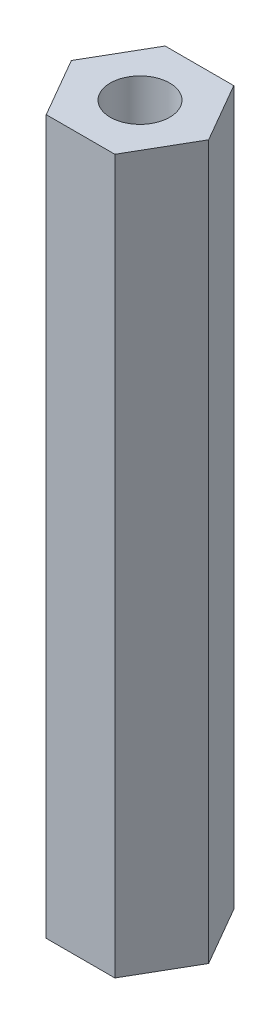
from build123d import *

# Parameters (mm, degrees)
SKETCH1_R           = 3.175
BOSS_EXTRUDE1_DEPTH = 38.1


with BuildPart() as part:
    # Sketch1 → Boss-Extrude1 (new body, symmetric)
    with BuildSketch(Plane(origin=(0, 0, 0), x_dir=(1, 0, 0), z_dir=(0, 1, 0))):
        Polygon((3.666174209, -6.35), (7.332348419, 0), (3.666174209, 6.35), (-3.666174209, 6.35), (-7.332348419, 0), (-3.666174209, -6.35), align=None)
        Circle(SKETCH1_R, mode=Mode.SUBTRACT)
    extrude(amount=BOSS_EXTRUDE1_DEPTH, both=True)


solid = part.part
